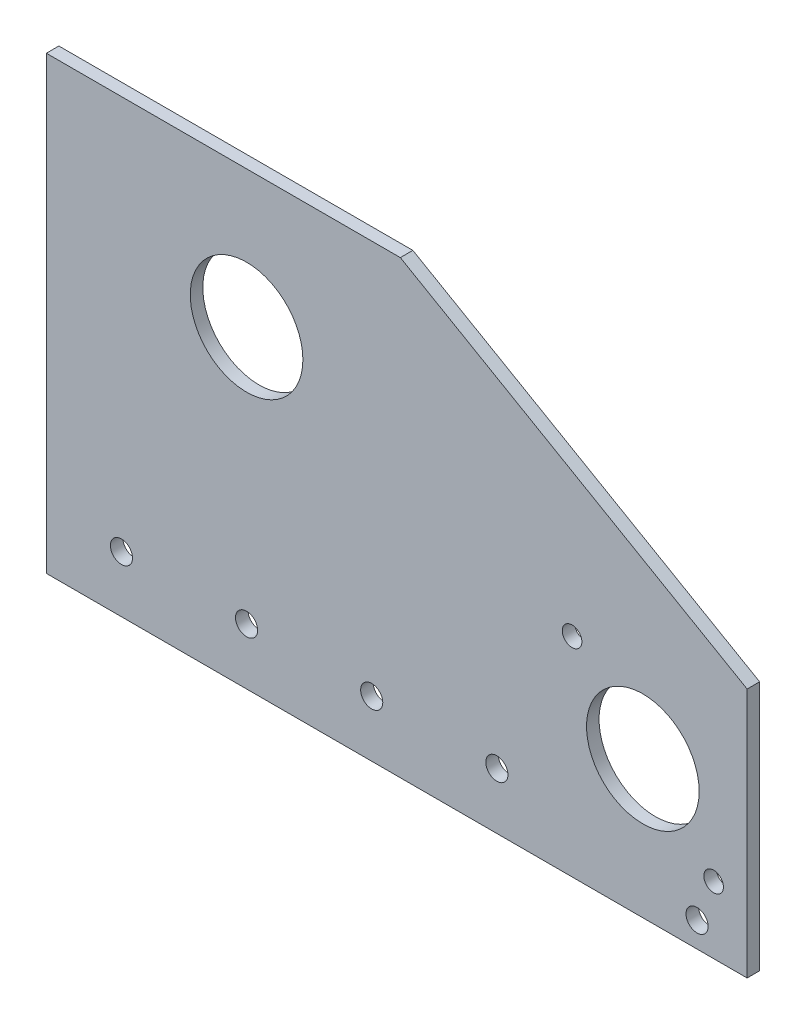
from build123d import *

# Parameters (mm, degrees)
SKETCH1_W              = 177.8
SKETCH1_H              = 114.3
BOSS_EXTRUDE1_DEPTH    = 3.175
SKETCH2_R              = 14.2875
CUT_EXTRUDE1_DEPTH     = 3.175
F_10_CLEARANCE_HOLE1_D = 5.6134
SKETCH5_R              = 14.2875
SKETCH5_R_2            = 2.4892
CUT_EXTRUDE2_DEPTH     = 4.175
CHAMFER1_SIZE          = 50.8
CHAMFER1_SIZE2         = 87.988181024
F_10_CLEARANCE_HOLE2_D = 5.6134


with BuildPart() as part:
    # Sketch1 → Boss-Extrude1 (new body)
    with BuildSketch(Plane.XY):
        Rectangle(SKETCH1_W, SKETCH1_H)
    extrude(amount=BOSS_EXTRUDE1_DEPTH)

    # Sketch2 → Cut-Extrude1 (cut)
    with BuildSketch(Plane.XY.offset(3.175)):
        with Locations((-38.1, 22.352)):
            Circle(SKETCH2_R)
    extrude(amount=-CUT_EXTRUDE1_DEPTH, mode=Mode.SUBTRACT)

    # #10 Clearance Hole1 (through all)
    with Locations(Plane.XY.offset(3.175)):
        with Locations((-69.85, -42.8625), (-38.1, -42.8625), (-6.35, -42.8625), (25.4, -42.8625)):
            Hole(F_10_CLEARANCE_HOLE1_D / 2)

    # Sketch5 → Cut-Extrude2 (cut, through all)
    with BuildSketch(Plane.XY.offset(3.175)):
        with Locations((62.443181743, -22.225)):
            Circle(SKETCH5_R)
        with Locations((44.482669501, -4.264487758)):
            Circle(SKETCH5_R_2)
        with Locations((80.403693985, -40.185512242)):
            Circle(SKETCH5_R_2)
    extrude(amount=-CUT_EXTRUDE2_DEPTH, mode=Mode.SUBTRACT)

    # Chamfer1
    chamfer1_edges = [part.edges().sort_by_distance(p)[0] for p in [
        (88.9, 57.15, 1.5875),
    ]]
    chamfer1_side = [part.faces().sort_by_distance(p)[0] for p in [
        (88.9, 0, 1.5875),
    ]]
    chamfer(chamfer1_edges, length=CHAMFER1_SIZE, length2=CHAMFER1_SIZE2, reference=chamfer1_side[0])

    # #10 Clearance Hole2 (through all)
    with Locations(Plane(origin=(0, 0, 0), x_dir=(-1, 0, 0), z_dir=(0, 0, -1))):
        with Locations((-76.2, -50.8)):
            Hole(F_10_CLEARANCE_HOLE2_D / 2)


solid = part.part
